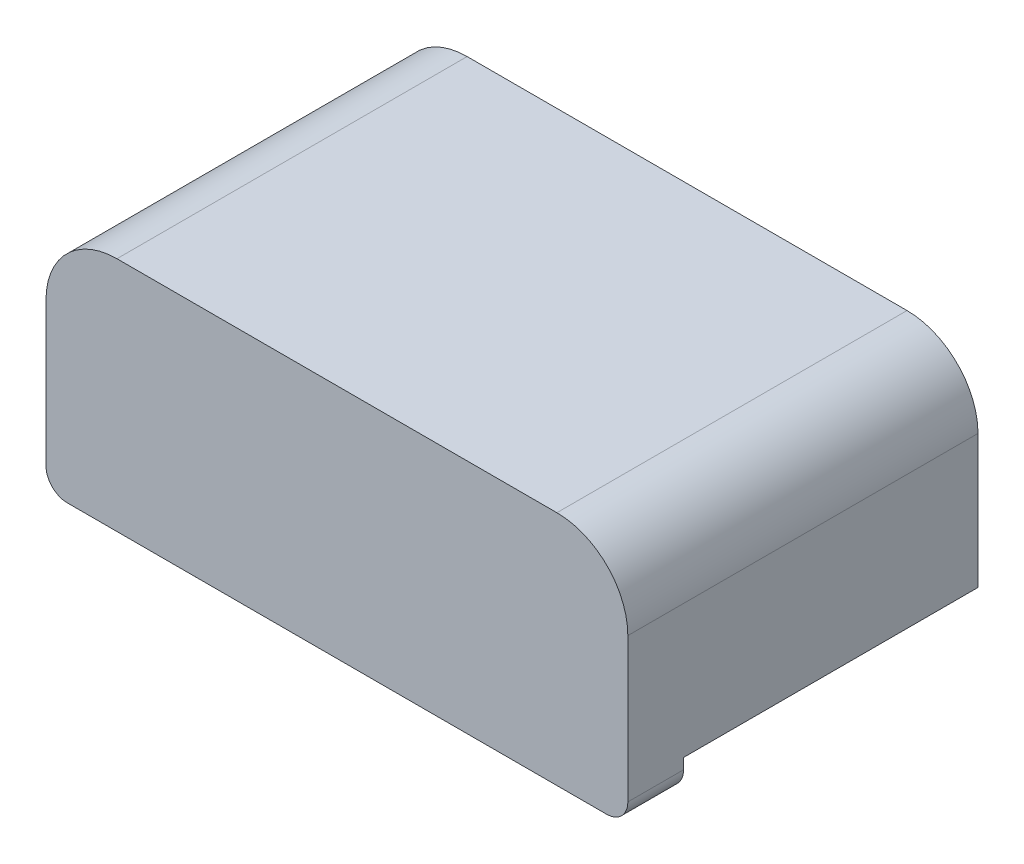
from build123d import *

# Parameters (mm, degrees)
SKETCH1_W           = 8.2
SKETCH1_H           = 3.33
BOSS_EXTRUDE1_DEPTH = 0.785
SKETCH2_W           = 8.2
SKETCH2_H           = 2.88
BOSS_EXTRUDE2_DEPTH = 4.15
FILLET1_R           = 1
FILLET2_R           = 0.3
SKETCH3_W           = 2
SKETCH3_H           = 3
BOSS_EXTRUDE3_DEPTH = 0.45


with BuildPart() as part:
    # Sketch1 → Boss-Extrude1 (new body)
    with BuildSketch(Plane.XY):
        with Locations((0, 1.215)):
            Rectangle(SKETCH1_W, SKETCH1_H)
    extrude(amount=BOSS_EXTRUDE1_DEPTH)

    # Sketch2 → Boss-Extrude2 (add)
    with BuildSketch(Plane(origin=(0, 0, 0), x_dir=(-1, 0, 0), z_dir=(0, 0, -1))):
        with Locations((0, 1.44)):
            Rectangle(SKETCH2_W, SKETCH2_H)
    extrude(amount=BOSS_EXTRUDE2_DEPTH)

    # Fillet1
    fillet1_edges = [part.edges().sort_by_distance(p)[0] for p in [
        (-4.1, 2.88, -1.6825),
        (4.1, 2.88, -1.6825),
    ]]
    fillet(fillet1_edges, radius=FILLET1_R)

    # Fillet2
    fillet2_edges = [part.edges().sort_by_distance(p)[0] for p in [
        (4.1, -0.45, 0.3925),
        (-4.1, -0.45, 0.3925),
    ]]
    fillet(fillet2_edges, radius=FILLET2_R)

    # Sketch3 → Boss-Extrude3 (add)
    with BuildSketch(Plane.XZ):
        with Locations((2.5, -1.5)):
            Rectangle(SKETCH3_W, SKETCH3_H)
        with Locations((-2.5, -1.5)):
            Rectangle(SKETCH3_W, SKETCH3_H)
    extrude(amount=BOSS_EXTRUDE3_DEPTH)


solid = part.part
